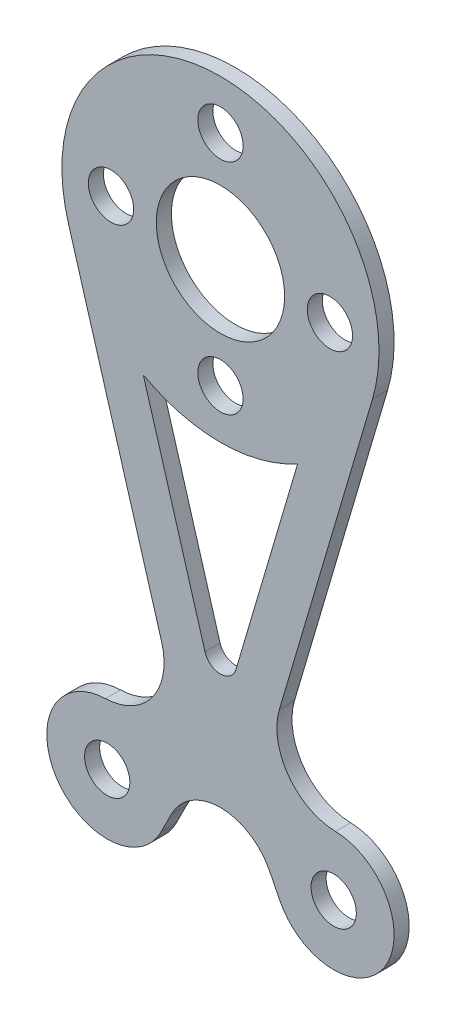
from build123d import *

# Parameters (mm, degrees)
SKETCH_1_R      = 1.5
SKETCH_1_R_2    = 4.25
EXTRUDE_1_DEPTH = 1


with BuildPart() as part:
    # 草图1 → 凸台-拉伸1 (new body)
    with BuildSketch(Plane.XY):
        with BuildLine():
            Line((-10.070213397, 30.026651359), (-3.9, 9.129214461))
            ThreePointArc((-3.9, 9.129214461), (-4.497287215, 5.649388777), (-7.618135885, 3.998255109))
            ThreePointArc((-7.618135885, 3.998255109), (-10.871519118, -2.152407684), (-3.922863507, -1.789998466))
            Line((-3.922863507, -1.789998466), (-3.251614082, -0.448572281))
            ThreePointArc((-3.251614082, -0.448572281), (0, 1.560317266), (3.251614082, -0.448572281))
            Line((3.251614082, -0.448572281), (3.922863507, -1.789998466))
            ThreePointArc((3.922863507, -1.789998466), (10.871519118, -2.152407684), (7.618135885, 3.998255109))
            ThreePointArc((7.618135885, 3.998255109), (4.497287215, 5.649388777), (3.9, 9.129214461))
            Line((3.9, 9.129214461), (10.070213397, 30.026651359))
            ThreePointArc((10.070213397, 30.026651359), (0, 43.5), (-10.070213397, 30.026651359))
        make_face()
        with Locations((-7.5, 0)):
            Circle(SKETCH_1_R, mode=Mode.SUBTRACT)
        with Locations((7.5, 0)):
            Circle(SKETCH_1_R, mode=Mode.SUBTRACT)
        with Locations((0, 33)):
            Circle(SKETCH_1_R_2, mode=Mode.SUBTRACT)
        with Locations((0, 40.25)):
            Circle(SKETCH_1_R, mode=Mode.SUBTRACT)
        with Locations((-7.25, 33)):
            Circle(SKETCH_1_R, mode=Mode.SUBTRACT)
        with Locations((0, 25.75)):
            Circle(SKETCH_1_R, mode=Mode.SUBTRACT)
        with Locations((7.25, 33)):
            Circle(SKETCH_1_R, mode=Mode.SUBTRACT)
        with BuildLine():
            Line((-5.112098998, 23.828498278), (-1.022796172, 9.978742645))
            ThreePointArc((-1.022796172, 9.978742645), (0, 9.214287127), (1.022796172, 9.978742645))
            Line((1.022796172, 9.978742645), (5.112098998, 23.828498278))
            ThreePointArc((5.112098998, 23.828498278), (0, 22.5), (-5.112098998, 23.828498278))
        make_face(mode=Mode.SUBTRACT)
    extrude(amount=EXTRUDE_1_DEPTH)


solid = part.part
